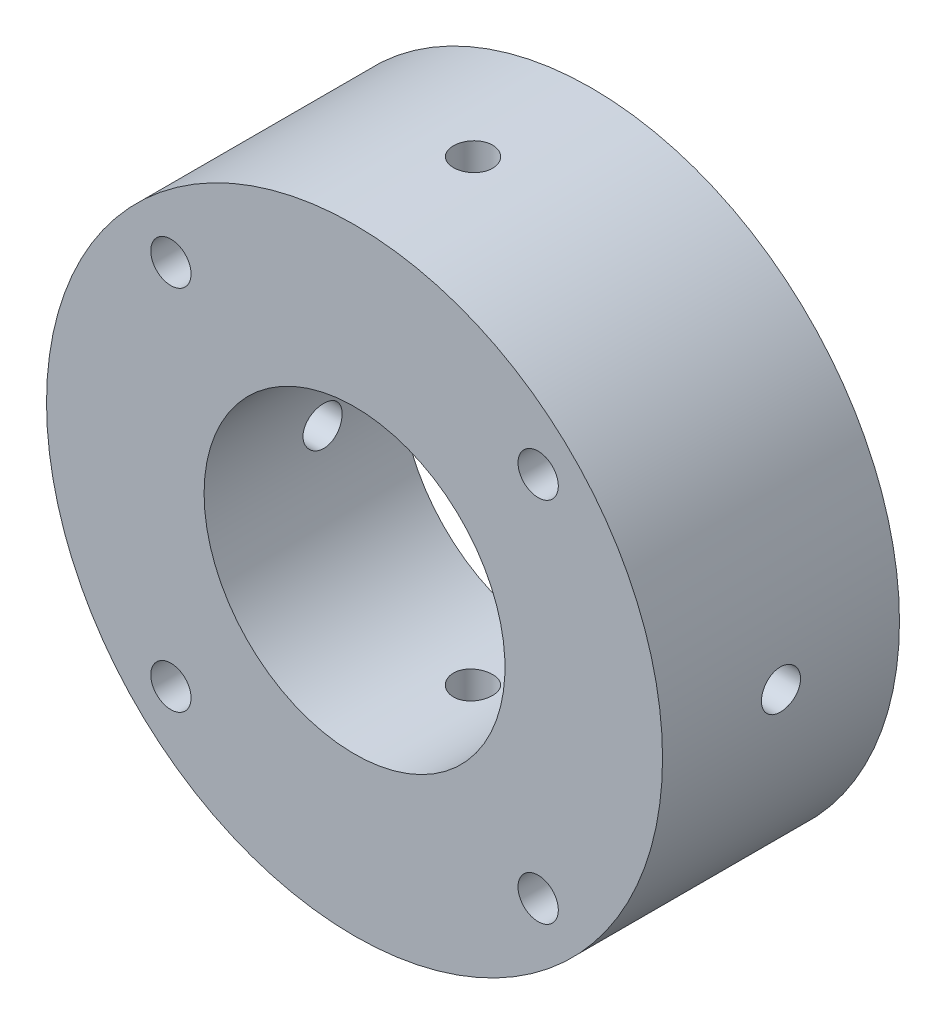
from build123d import *

# Parameters (mm, degrees)
SKETCH1_W                                           = 26
SKETCH1_H                                           = 20
F_2_CLEARANCE_HOLE1_D                               = 2.5
F_2_CLEARANCE_HOLE1_DEPTH                           = 6
HOLE1_D                                             = 25.4
HOLE1_DEPTH                                         = 20
HOLE1_CBORE_D                                       = 40
HOLE1_CBORE_DEPTH                                   = 3.4
F_4_CLEARANCE_HOLE1_D                               = 3.3
F_4_CLEARANCE_HOLE1_DEPTH                           = 65.407641206
F_4_CLEARANCE_HOLE2_D                               = 3.3
F_4_CLEARANCE_HOLE2_DEPTH                           = 13.407641206
F_4_CLEARANCE_HOLE3_D                               = 3.3
F_4_CLEARANCE_HOLE3_DEPTH                           = 13.407641206
CBORE_FOR_4_BINDING_HEAD_MACHINE_SCREW1_D           = 3.4
CBORE_FOR_4_BINDING_HEAD_MACHINE_SCREW1_DEPTH       = 20
CBORE_FOR_4_BINDING_HEAD_MACHINE_SCREW1_CBORE_D     = 6.5
CBORE_FOR_4_BINDING_HEAD_MACHINE_SCREW1_CBORE_DEPTH = 7.5


with BuildPart() as part:
    # Sketch1 → Revolve1 (revolve)
    with BuildSketch(Plane.XZ):
        with Locations((13, 10)):
            Rectangle(SKETCH1_W, SKETCH1_H)
    revolve(axis=Axis((0, 0, 20), (0, 0, -1)))

    # #2 Clearance Hole1
    with Locations(Plane(origin=(0, 0, 0), x_dir=(-1, 0, 0), z_dir=(0, 0, -1))):
        with Locations((-22.776165581, 3.200981322)):
            Hole(F_2_CLEARANCE_HOLE1_D / 2, depth=F_2_CLEARANCE_HOLE1_DEPTH)

    # Hole1
    with Locations(Plane(origin=(0, 0, 0), x_dir=(-1, 0, 0), z_dir=(0, 0, -1))):
        with Locations((0, 0)):
            CounterBoreHole(HOLE1_D / 2, HOLE1_CBORE_D / 2, HOLE1_CBORE_DEPTH, depth=HOLE1_DEPTH)

    # #4 Clearance Hole1
    with Locations(Plane(origin=(26, 0, 10), x_dir=(0, 1, 0), z_dir=(1, 0, 0))):
        with Locations((0, 0)):
            Hole(F_4_CLEARANCE_HOLE1_D / 2, depth=F_4_CLEARANCE_HOLE1_DEPTH)

    # #4 Clearance Hole2
    with Locations(Plane(origin=(0, 12.592358794, 0), x_dir=(-1, 0, 0), z_dir=(0, -1, 0))):
        with Locations((0, -10)):
            Hole(F_4_CLEARANCE_HOLE2_D / 2, depth=F_4_CLEARANCE_HOLE2_DEPTH)

    # #4 Clearance Hole3
    with Locations(Plane(origin=(0, -12.592358794, 0), x_dir=(1, 0, 0), z_dir=(0, 1, 0))):
        with Locations((0, -10)):
            Hole(F_4_CLEARANCE_HOLE3_D / 2, depth=F_4_CLEARANCE_HOLE3_DEPTH)

    # CBORE for #4 Binding Head Machine Screw1
    with Locations(Plane(origin=(0, 0, 0), x_dir=(-1, 0, 0), z_dir=(0, 0, -1))):
        with Locations((-15.5, -15.5), (15.5, -15.5), (15.5, 15.5), (-15.5, 15.5)):
            CounterBoreHole(CBORE_FOR_4_BINDING_HEAD_MACHINE_SCREW1_D / 2, CBORE_FOR_4_BINDING_HEAD_MACHINE_SCREW1_CBORE_D / 2, CBORE_FOR_4_BINDING_HEAD_MACHINE_SCREW1_CBORE_DEPTH, depth=CBORE_FOR_4_BINDING_HEAD_MACHINE_SCREW1_DEPTH)


solid = part.part
